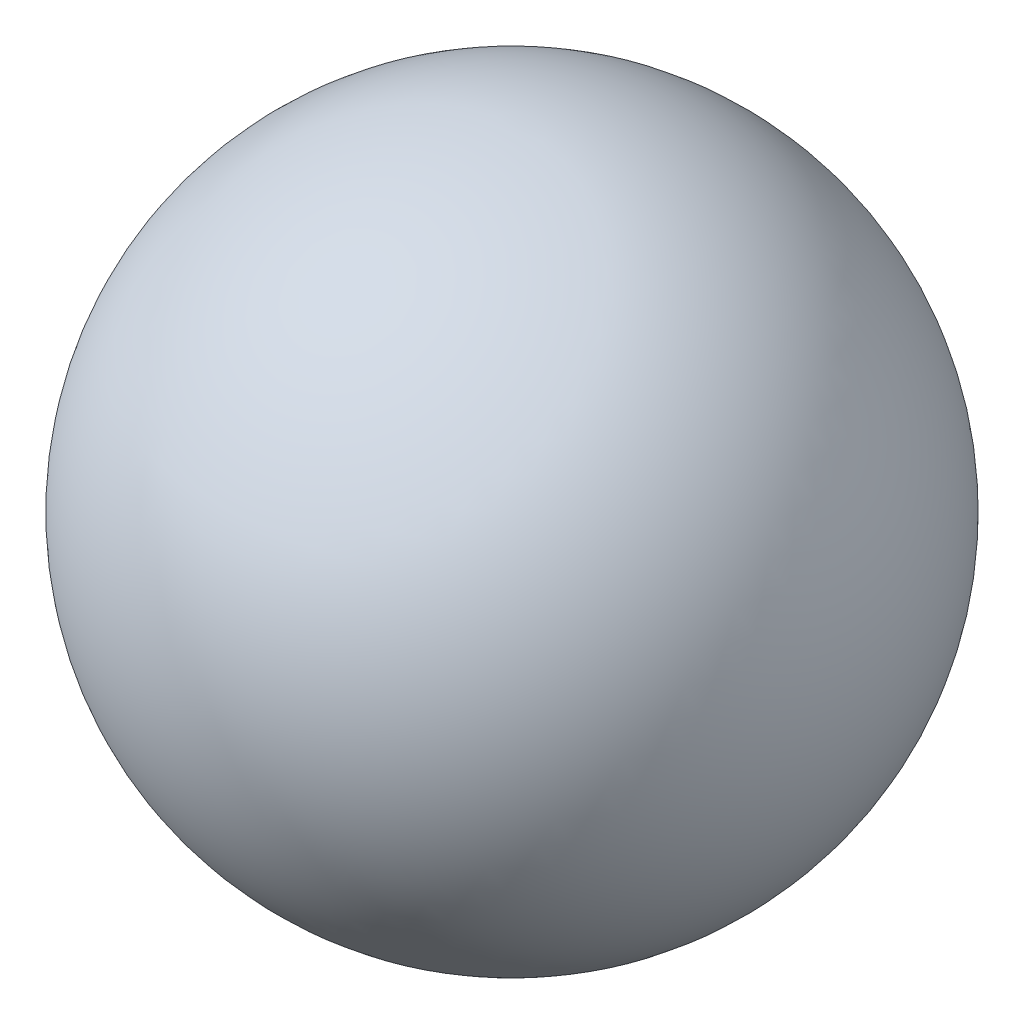
from build123d import *


with BuildPart() as part:
    # 草圖1 → 旋轉1 (revolve)
    with BuildSketch(Plane.XY):
        with BuildLine():
            Line((0, 0), (0, 39))
            ThreePointArc((0, 39), (19.5, 19.5), (0, 0))
        make_face()
    revolve(axis=Axis((0, 0, 0), (0, 1, 0)))


solid = part.part
